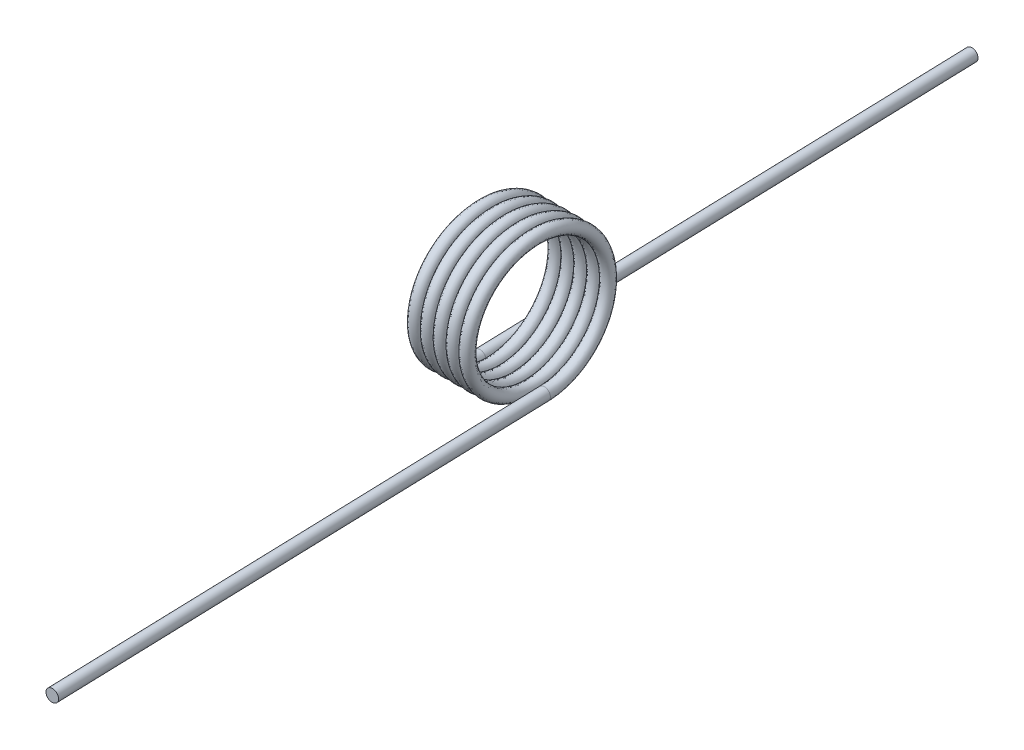
from build123d import *

# Parameters (mm, degrees)
SWEEP1_PITCH       = 0.4826
SWEEP1_HEIGHT      = 2.413
SWEEP1_RADIUS      = 2.5146
SWEEP1_START_ANGLE = 90
SKETCH3_R          = 0.2286
SKETCH4_R          = 0.2286
EXTRUDE1_DEPTH     = 19.05
SKETCH5_R          = 0.2286
EXTRUDE2_DEPTH     = 19.05


with BuildPart() as part:
    # Sweep1: sweep along a helix
    with BuildLine() as sweep1_path:
        add(Helix(SWEEP1_PITCH, SWEEP1_HEIGHT, SWEEP1_RADIUS, center=(0, 0, 0), direction=(-1, 0, 0), lefthand=True, mode=Mode.PRIVATE).rotate(Axis((0, 0, 0), (-1, 0, 0)), SWEEP1_START_ANGLE))
    # Sketch3 → Sweep1 (sweep)
    with BuildSketch(Plane(origin=(0, -2.5146, 0), x_dir=(0.999263962, -0.023236129, -0.030522406), z_dir=(-0.030530649, 0, -0.999533831))):
        Circle(SKETCH3_R)
    sweep(path=sweep1_path.line, is_frenet=True)

    # Sketch4 → Extrude1 (add)
    with BuildSketch(Plane(origin=(0, 0, 0), x_dir=(-0.999263962, 0.023236129, 0.030522406), z_dir=(0.030530649, 0, 0.999533831))):
        with Locations((-0.05842957, 2.51392107)):
            Circle(SKETCH4_R)
    extrude(amount=EXTRUDE1_DEPTH)

    # Sketch5 → Extrude2 (add)
    with BuildSketch(Plane(origin=(-0.002249207, 0, -0.073636113), x_dir=(0.998584064, 0.043583445, -0.030501638), z_dir=(-0.030530649, 0, -0.999533831))):
        with Locations((-2.519178278, 2.407092775)):
            Circle(SKETCH5_R)
    extrude(amount=EXTRUDE2_DEPTH)


solid = part.part
